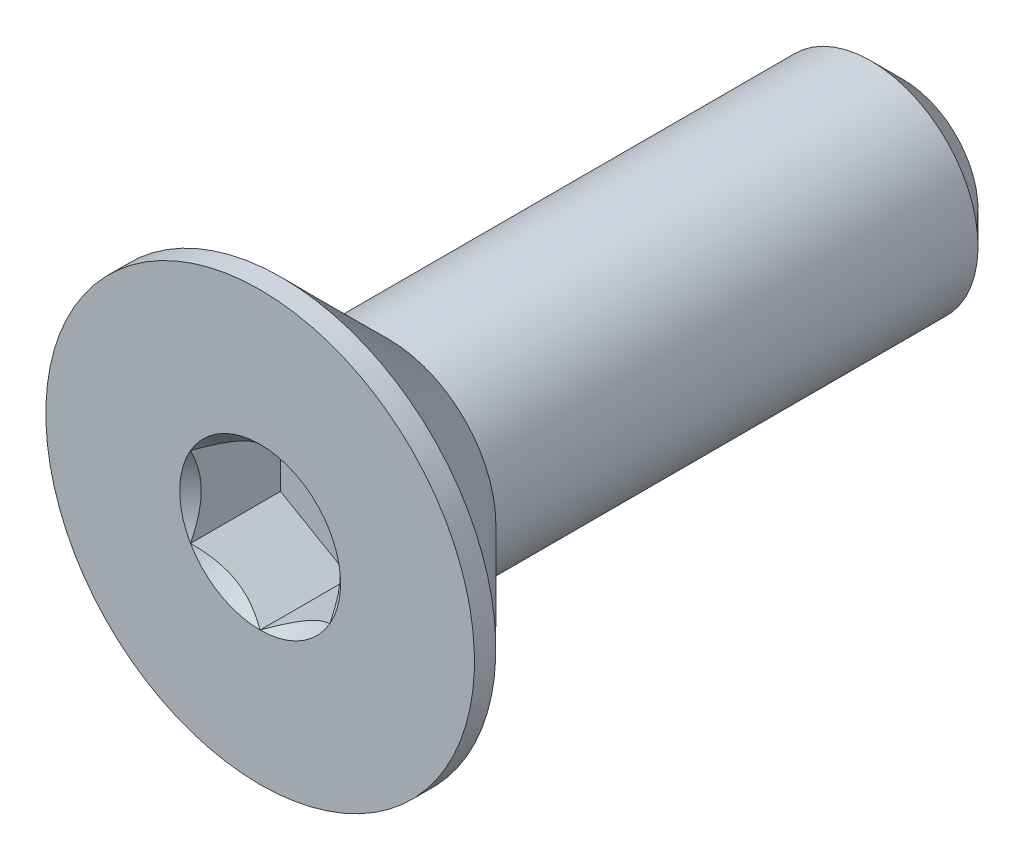
from build123d import *

# Parameters (mm, degrees)
SKETCH1_W          = 6
SKETCH1_H          = 1
CHAMFER1_SIZE      = 0.3
CUT_EXTRUDE2_DEPTH = 0.84


with BuildPart() as part:
    # Sketch1 → Revolve1 (revolve)
    with BuildSketch(Plane(origin=(0, 0, 0), x_dir=(0, 0, -1), z_dir=(1, 0, 0))):
        with Locations((3, 0.5)):
            Rectangle(SKETCH1_W, SKETCH1_H)
    revolve(axis=Axis((0, 0, -6), (0, 0, 1)))

    # Chamfer1
    chamfer1_edges = [part.edges().sort_by_distance(p)[0] for p in [
        (0, -1, -6),
    ]]
    chamfer(chamfer1_edges, length=CHAMFER1_SIZE)

    # Sketch7 → Revolve2 (revolve)
    with BuildSketch(Plane(origin=(0, 0, 0), x_dir=(0, 0, -1), z_dir=(1, 0, 0)), mode=Mode.PRIVATE) as revolve2_sk:
        Polygon((0, 2), (0.2, 2), (1.2, 1), (1.2, 0), (0, 0), align=None)
    revolve(revolve2_sk.sketch.rotate(Axis((0, 0, 0), (0, 0, -1)), 180), axis=Axis((0, 0, 0), (0, 0, -1)))

    # Boss-Extrude1 cone 1 section (through the dimple's axis) → Boss-Extrude1 (revolve)
    with BuildSketch(Plane(origin=(0, 0, -1.2), x_dir=(0, -1, 0), z_dir=(1, 0, 0))):
        Polygon((0, 0), (1, 0), (0, 1), align=None)
    revolve(axis=Axis((0, 0, -1.2), (0, 0, -1)))

    # Sketch5 → Cut-Extrude2 (cut)
    with BuildSketch(Plane.XY):
        Polygon((0.65, -0.375277675), (0.65, 0.375277675), (0, 0.75055535), (-0.65, 0.375277675), (-0.65, -0.375277675), (0, -0.75055535), align=None)
    extrude(amount=-CUT_EXTRUDE2_DEPTH, mode=Mode.SUBTRACT)

    # Cut-Extrude3 cone 1 section (through the dimple's axis) → Cut-Extrude3 (revolve, cut)
    with BuildSketch(Plane(origin=(0, 0, 0), x_dir=(0, -1, 0), z_dir=(1, 0, 0))):
        Polygon((0, 0), (0.75055535, 0), (0, 0.75055535), align=None)
    revolve(axis=Axis((0, 0, 0), (0, 0, -1)), mode=Mode.SUBTRACT)


solid = part.part
